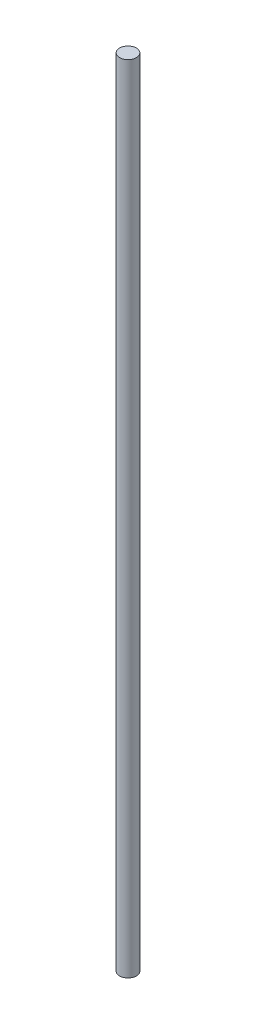
from build123d import *

# Parameters (mm, degrees)
SKETCH1_R           = 4
BOSS_EXTRUDE1_DEPTH = 380


with BuildPart() as part:
    # Sketch1 → Boss-Extrude1 (new body)
    with BuildSketch(Plane(origin=(0, 0, 0), x_dir=(1, 0, 0), z_dir=(0, 1, 0))):
        Circle(SKETCH1_R)
    extrude(amount=BOSS_EXTRUDE1_DEPTH)


solid = part.part
